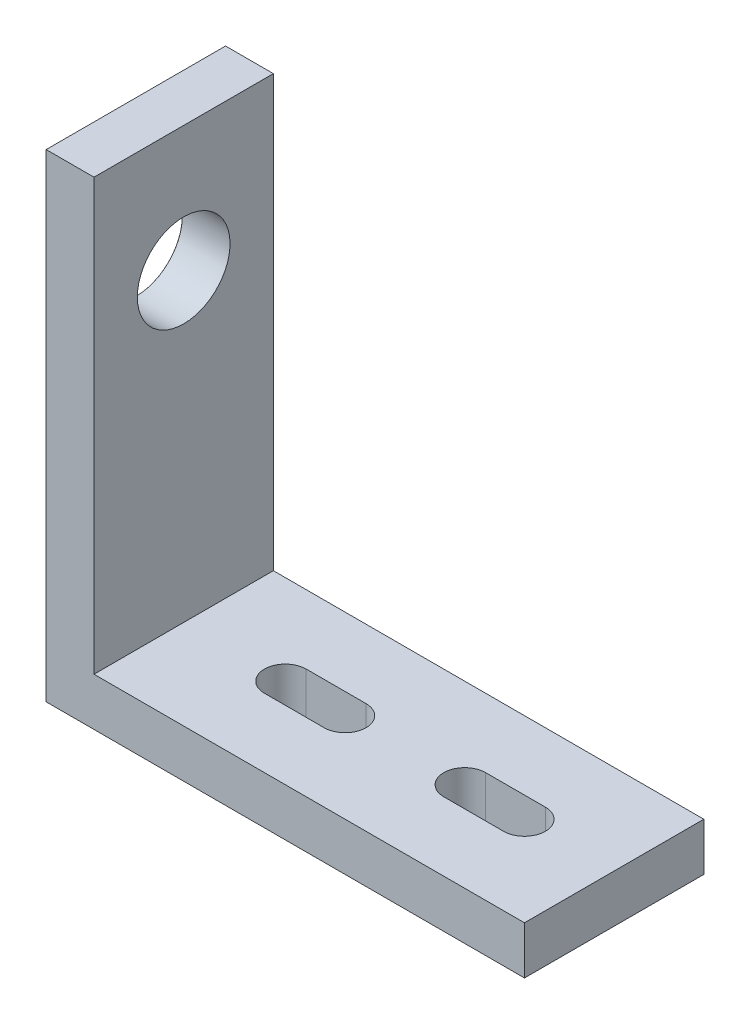
from build123d import *

# Parameters (mm, degrees)
EXTRUDE_1_DEPTH                     = 30
CUT_EXTRUDE_1_DEPTH                 = 60
HOLE_WIZARD_15_5_15_5_1_D           = 15.5
HOLE_WIZARD_15_5_15_5_1_DEPTH       = 17
HOLE_WIZARD_15_5_15_5_1_CSINK_D     = 15.55
HOLE_WIZARD_15_5_15_5_1_CSINK_ANGLE = 90
HOLE_WIZARD_15_5_15_5_1_TIP         = 4.656669797


with BuildPart() as part:
    # 草图1 → 凸台-拉伸1 (new body)
    with BuildSketch(Plane.XY):
        Polygon((0, 80), (0, 0), (80, 0), (80, 8), (8, 8), (8, 80), align=None)
    extrude(amount=EXTRUDE_1_DEPTH)

    # 草图2 → 切除-拉伸1 (cut)
    with BuildSketch(Plane(origin=(0, 8, 0), x_dir=(1, 0, 0), z_dir=(0, 1, 0))):
        with BuildLine():
            Line((55, -11.5), (65, -11.5))
            ThreePointArc((65, -11.5), (68.5, -15), (65, -18.5))
            Line((65, -18.5), (55, -18.5))
            ThreePointArc((55, -18.5), (51.5, -15), (55, -11.5))
        make_face()
        with BuildLine():
            Line((25, -11.5), (35, -11.5))
            ThreePointArc((35, -11.5), (38.5, -15), (35, -18.5))
            Line((35, -18.5), (25, -18.5))
            ThreePointArc((25, -18.5), (21.5, -15), (25, -11.5))
        make_face()
    extrude(amount=-CUT_EXTRUDE_1_DEPTH, mode=Mode.SUBTRACT)

    # Ø15.5 (15.5) 直径槽口1
    with Locations(Plane.ZY):
        with Locations((15, 59)):
            CounterSinkHole(HOLE_WIZARD_15_5_15_5_1_D / 2, HOLE_WIZARD_15_5_15_5_1_CSINK_D / 2, depth=HOLE_WIZARD_15_5_15_5_1_DEPTH, counter_sink_angle=HOLE_WIZARD_15_5_15_5_1_CSINK_ANGLE)
            with Locations((0, 0, -(HOLE_WIZARD_15_5_15_5_1_DEPTH + HOLE_WIZARD_15_5_15_5_1_TIP / 2))):  # 118° drill point
                Cone(0, HOLE_WIZARD_15_5_15_5_1_D / 2, HOLE_WIZARD_15_5_15_5_1_TIP, mode=Mode.SUBTRACT)


solid = part.part
